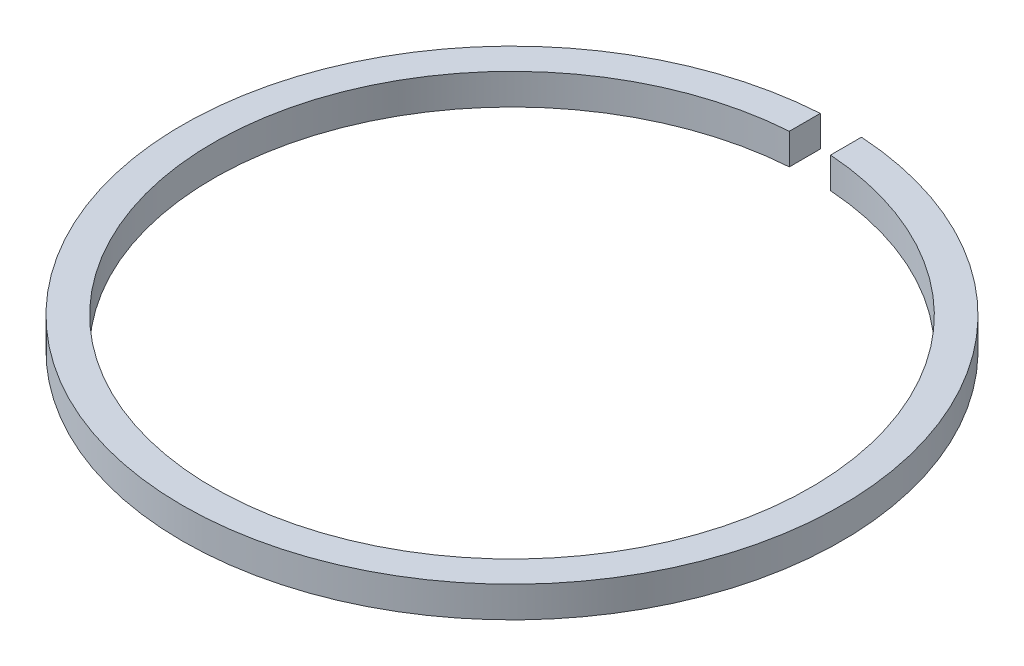
from build123d import *

# Parameters (mm, degrees)
BOSS_EXTRUDE1_DEPTH = 1.5


with BuildPart() as part:
    # Sketch1 → Boss-Extrude1 (new body)
    with BuildSketch(Plane(origin=(0, 0, 0), x_dir=(1, 0, 0), z_dir=(0, 1, 0))):
        with BuildLine():
            Line((-1, 14.465476141), (-1, 15.968719423))
            ThreePointArc((-1, 15.968719423), (0, -16), (1, 15.968719423))
            Line((1, 15.968719423), (1, 14.465476141))
            ThreePointArc((1, 14.465476141), (0, -14.5), (-1, 14.465476141))
        make_face()
    extrude(amount=BOSS_EXTRUDE1_DEPTH)


solid = part.part
